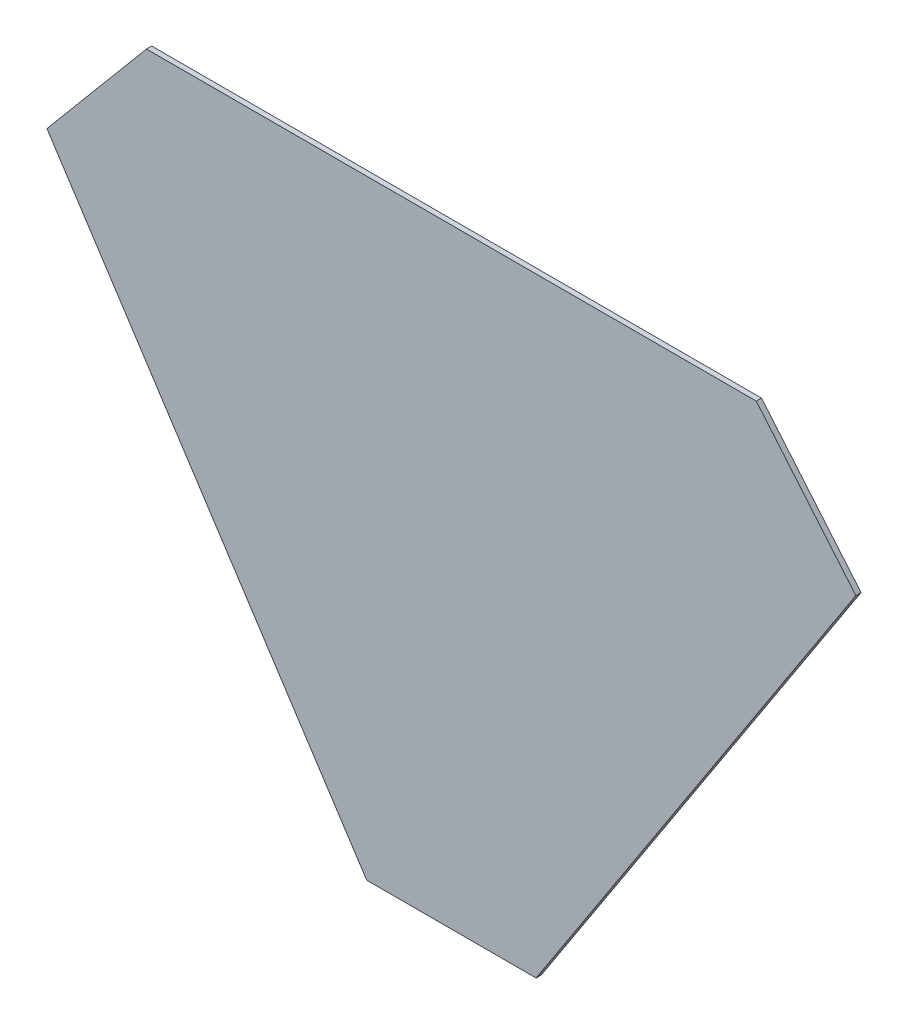
from build123d import *

# Parameters (mm, degrees)
BOSS_EXTRU_1_DEPTH = 1


with BuildPart() as part:
    # Esquisse1 → Boss.-Extru.1 (new body)
    with BuildSketch(Plane.XY):
        Polygon((183.420664961, 103.133180924), (202.536172587, 80.352206037), (141.143894058, -13.924152046), (108.624666053, -13.924152046), (47.232387524, 80.352206037), (66.34789515, 103.133180924), align=None)
    extrude(amount=BOSS_EXTRU_1_DEPTH)


solid = part.part
